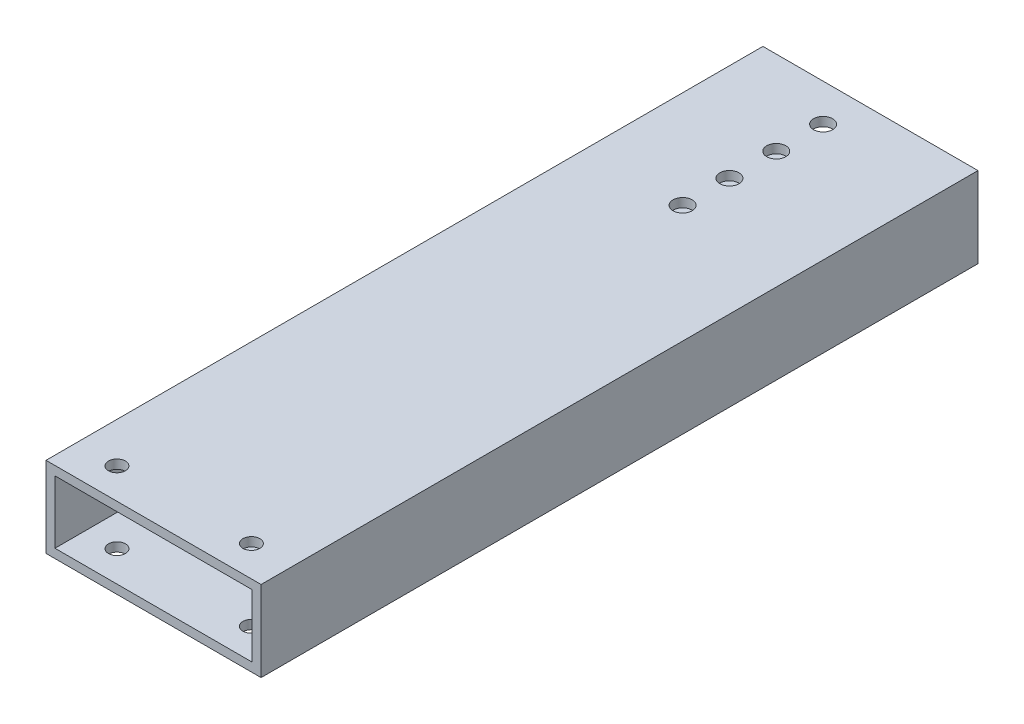
from build123d import *

# Parameters (mm, degrees)
SKETCH1_W           = 76.2
SKETCH1_H           = 254
BOSS_EXTRUDE1_DEPTH = 3.175
SKETCH2_W           = 3.175
SKETCH2_H           = 254
BOSS_EXTRUDE2_DEPTH = 25.4
BOSS_EXTRUDE3_REACH = 75.025
SKETCH3_W           = 254
SKETCH3_H           = 3.175
SKETCH4_R           = 3.3782
CUT_EXTRUDE1_DEPTH  = 29.575
SKETCH5_R           = 3
CUT_EXTRUDE2_DEPTH  = 29.575


with BuildPart() as part:
    # Sketch1 → Boss-Extrude1 (new body)
    with BuildSketch(Plane(origin=(0, 0, 0), x_dir=(1, 0, 0), z_dir=(0, 1, 0))):
        with Locations((38.1, 127)):
            Rectangle(SKETCH1_W, SKETCH1_H)
    extrude(amount=BOSS_EXTRUDE1_DEPTH)

    # Sketch2 → Boss-Extrude2 (add)
    with BuildSketch(Plane(origin=(0, 3.175, 0), x_dir=(1, 0, 0), z_dir=(0, 1, 0))):
        with Locations((1.5875, 127)):
            Rectangle(SKETCH2_W, SKETCH2_H)
        with Locations((74.6125, 127)):
            Rectangle(SKETCH2_W, SKETCH2_H)
    extrude(amount=BOSS_EXTRUDE2_DEPTH)

    # Sketch3 → Boss-Extrude3 (add, up to next)
    with BuildSketch(Plane(origin=(3.175, 0, 0), x_dir=(0, 0, -1), z_dir=(1, 0, 0)), mode=Mode.PRIVATE) as boss_extrude3_sk1:
        with Locations((127, 26.9875)):
            Rectangle(SKETCH3_W, SKETCH3_H)
    boss_extrude3_tool1 = extrude(boss_extrude3_sk1.sketch, amount=BOSS_EXTRUDE3_REACH, mode=Mode.PRIVATE) - part.part
    add(boss_extrude3_tool1.solids().sort_by_distance((3.175, 26.9875, -127))[0])

    # Sketch4 → Cut-Extrude1 (cut, through all)
    with BuildSketch(Plane.XZ):
        with Locations((34.5313, -191.01308)):
            Circle(SKETCH4_R)
        with Locations((34.5313, -207.60436)):
            Circle(SKETCH4_R)
        with Locations((34.5313, -224.19564)):
            Circle(SKETCH4_R)
        with Locations((34.5313, -240.78692)):
            Circle(SKETCH4_R)
    extrude(amount=-CUT_EXTRUDE1_DEPTH, mode=Mode.SUBTRACT)

    # Sketch5 → Cut-Extrude2 (cut, through all)
    with BuildSketch(Plane(origin=(0, 28.575, 0), x_dir=(1, 0, 0), z_dir=(0, 1, 0))):
        with Locations((14.2875, 10.852567875)):
            Circle(SKETCH5_R)
        with Locations((61.9125, 10.852567875)):
            Circle(SKETCH5_R)
    extrude(amount=-CUT_EXTRUDE2_DEPTH, mode=Mode.SUBTRACT)


solid = part.part
